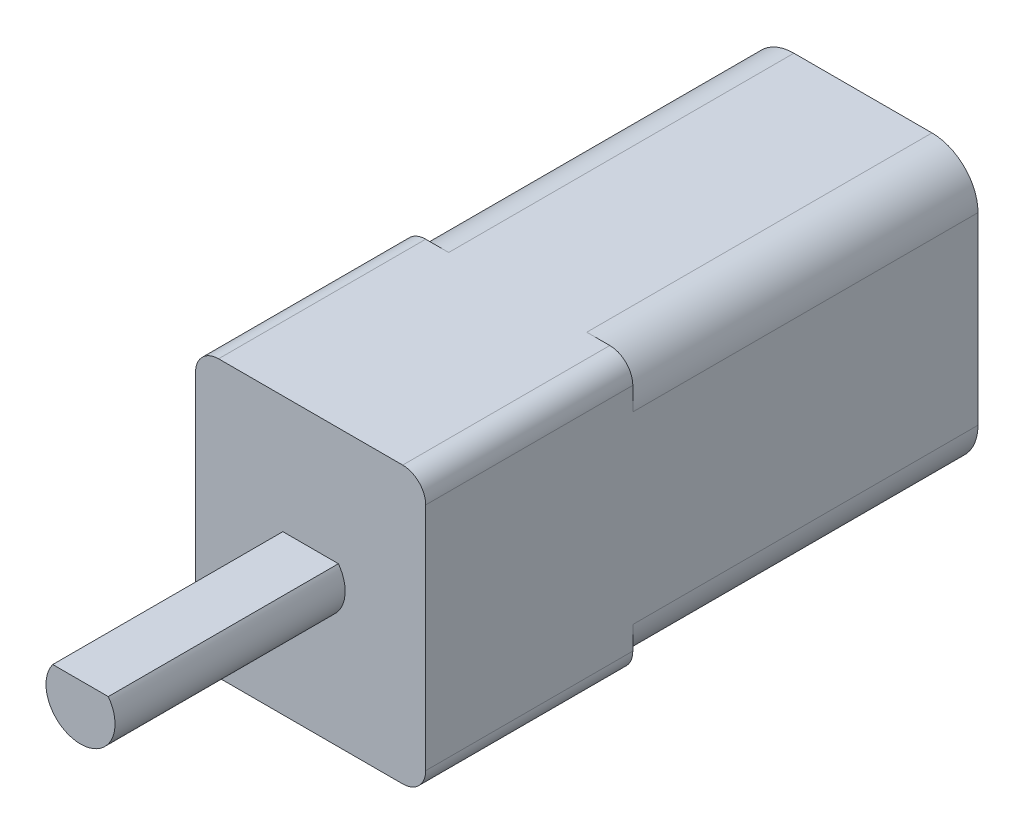
from build123d import *

# Parameters (mm, degrees)
BOSS_EXTRUDE1_DEPTH = 15
BOSS_EXTRUDE2_DEPTH = 9
BOSS_EXTRUDE3_DEPTH = 10


with BuildPart() as part:
    # Sketch1 → Boss-Extrude1 (new body)
    with BuildSketch(Plane.XY):
        with BuildLine():
            Line((2, 0), (8, 0))
            ThreePointArc((8, 0), (9.414213562, 0.585786438), (10, 2))
            Line((10, 2), (10, 10))
            ThreePointArc((10, 10), (9.414213562, 11.414213562), (8, 12))
            Line((8, 12), (2, 12))
            ThreePointArc((2, 12), (0.585786438, 11.414213562), (0, 10))
            Line((0, 10), (0, 2))
            ThreePointArc((0, 2), (0.585786438, 0.585786438), (2, 0))
        make_face()
    extrude(amount=BOSS_EXTRUDE1_DEPTH)

    # Sketch2 → Boss-Extrude2 (add)
    with BuildSketch(Plane.XY.offset(15)):
        with BuildLine():
            Line((1, 0), (9, 0))
            ThreePointArc((9, 0), (9.707106781, 0.292893219), (10, 1))
            Line((10, 1), (10, 11))
            ThreePointArc((10, 11), (9.707106781, 11.707106781), (9, 12))
            Line((9, 12), (1, 12))
            ThreePointArc((1, 12), (0.292893219, 11.707106781), (0, 11))
            Line((0, 11), (0, 1))
            ThreePointArc((0, 1), (0.292893219, 0.292893219), (1, 0))
        make_face()
    extrude(amount=BOSS_EXTRUDE2_DEPTH)

    # Sketch3 → Boss-Extrude3 (add)
    with BuildSketch(Plane.XY.offset(24)):
        with BuildLine():
            Line((6.206664687, 6.891044518), (3.793335313, 6.891044518))
            ThreePointArc((3.793335313, 6.891044518), (4.530956841, 4.575219836), (6.5, 6))
            ThreePointArc((6.5, 6), (6.424780164, 6.469043159), (6.206664687, 6.891044518))
        make_face()
    extrude(amount=BOSS_EXTRUDE3_DEPTH)


solid = part.part
